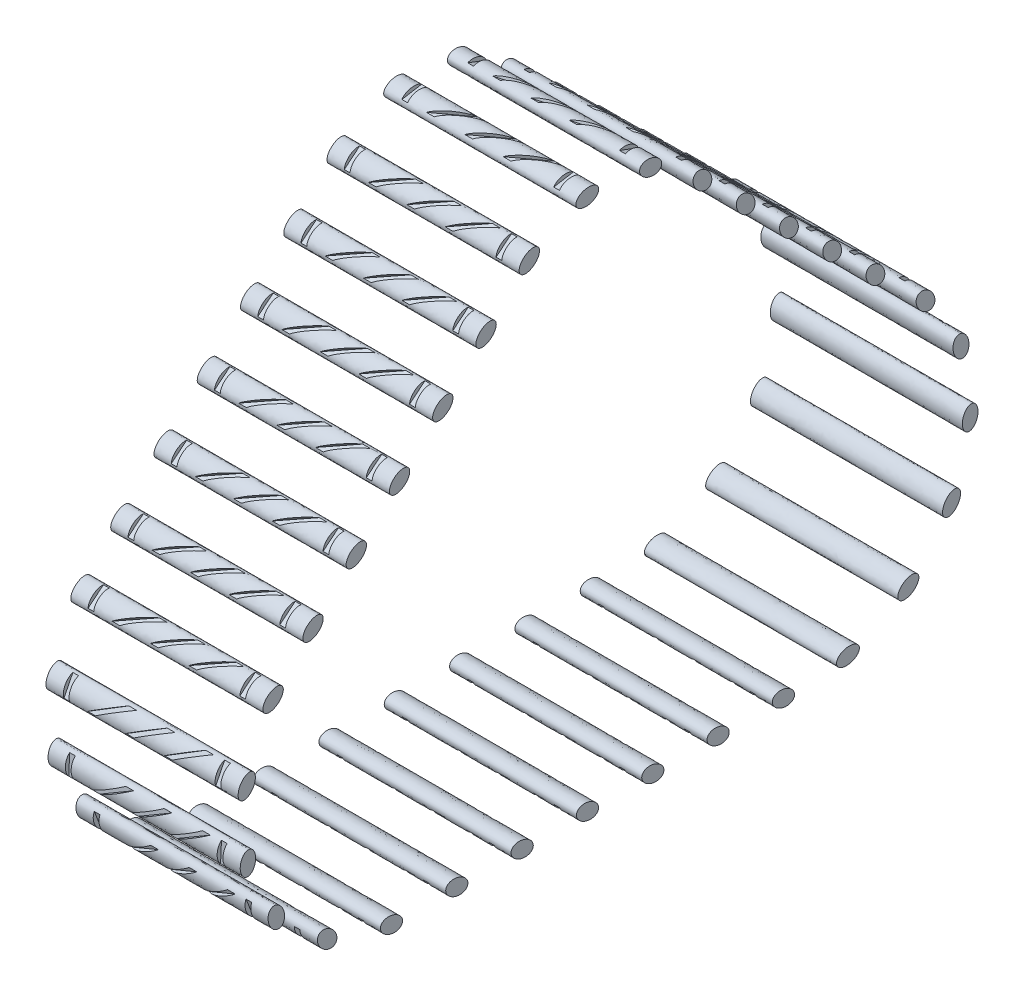
from build123d import *

# Parameters (mm, degrees)
SKETCH_2_RX              = 3
SKETCH_2_RY              = 2
EXTRUDE_1_DEPTH          = 50
SKETCH_5_W               = 1.5
SKETCH_5_H               = 1
CUT_EXTRUDE_2_DEPTH      = 25
CUT_EXTRUDE_4_DEPTH      = 25
PATTERN_LINEAR_1_COUNT   = 2
PATTERN_LINEAR_1_PITCH   = 10
PATTERN_LINEAR_2_COUNT   = 2
PATTERN_LINEAR_2_PITCH   = 10
PATTERN_CIRCULAR_3_COUNT = 3
PATTERN_CIRCULAR_3_ANGLE = 60
PATTERN_CIRCULAR_4_COUNT = 2
PATTERN_CIRCULAR_4_ANGLE = 30
PATTERN_LINEAR_3_COUNT   = 6
PATTERN_LINEAR_3_PITCH   = 15.7
PATTERN_LINEAR_4_COUNT   = 5
PATTERN_LINEAR_4_PITCH   = 15.7
PATTERN_LINEAR_5_COUNT   = 2
PATTERN_LINEAR_5_PITCH   = 15
PATTERN_CIRCULAR_5_COUNT = 6
PATTERN_CIRCULAR_5_ANGLE = 120
PATTERN_LINEAR_6_COUNT   = 2
PATTERN_LINEAR_6_PITCH   = 18
PATTERN_CIRCULAR_6_COUNT = 6
PATTERN_CIRCULAR_6_ANGLE = 120
PATTERN_LINEAR_7_COUNT   = 7
PATTERN_LINEAR_7_PITCH   = 17


with BuildPart() as part:
    # Sketch 2 → Extrude 1 (new body)
    with BuildSketch(Plane(origin=(0, 0, 0), x_dir=(0, 0, -1), z_dir=(1, 0, 0))):
        with Locations(Location((-5.2411758, 96.567762113), (0, 0, 8.868937921))):
            Ellipse(SKETCH_2_RX, SKETCH_2_RY)
    extrude(amount=EXTRUDE_1_DEPTH)

    # Sketch 5 → Cut-Extrude 2 (cut, symmetric)
    with BuildSketch(Plane(origin=(0, 1.757367098, -10.542320534), x_dir=(1, 0, 0), z_dir=(0, -0.164427543, 0.986389164))):
        with Locations((5.25, 97.615322624)):
            Rectangle(SKETCH_5_W, SKETCH_5_H)
    cut_extrude_2 = extrude(amount=CUT_EXTRUDE_2_DEPTH, both=True, mode=Mode.SUBTRACT)

    # Mirror 2: Cut-Extrude 2 across plane
    add(cut_extrude_2.mirror(Plane(origin=(25, 0, 0), x_dir=(0, 0, 1), z_dir=(1, 0, 0))), mode=Mode.SUBTRACT)

    # Sketch 7 → Cut-Extrude 4 (cut, symmetric)
    with BuildSketch(Plane(origin=(23.377948952, 2.219322141, -13.31355606), x_dir=(0.5, -0.142398429, 0.854238074), z_dir=(-0.866025404, -0.082213771, 0.493194582))):
        Polygon((3.244102096, 98.345137773), (4.244102028, 98.34550487), (4.244102028, 97.264960027), (3.244102096, 97.264960027), align=None)
    cut_extrude_4 = extrude(amount=CUT_EXTRUDE_4_DEPTH, both=True, mode=Mode.SUBTRACT)

    # Pattern Linear 1: Cut-Extrude 4 ×2
    with Locations(*[(i * PATTERN_LINEAR_1_PITCH, 0, 0) for i in range(1, PATTERN_LINEAR_1_COUNT)]):
        add(cut_extrude_4, mode=Mode.SUBTRACT)

    # Pattern Linear 2: Cut-Extrude 4 ×2
    with Locations(*[(-i * PATTERN_LINEAR_2_PITCH, 0, 0) for i in range(1, PATTERN_LINEAR_2_COUNT)]):
        add(cut_extrude_4, mode=Mode.SUBTRACT)


with BuildPart() as pattern_circular_3_1:
    # Pattern Circular 3: pattern copy
    add(part.part.rotate(Axis((0, 65, 0), (-1, 0, 0)), 1 * PATTERN_CIRCULAR_3_ANGLE / (PATTERN_CIRCULAR_3_COUNT - 1)))


with BuildPart() as pattern_circular_3_2:
    # Pattern Circular 3: pattern copy
    add(part.part.rotate(Axis((0, 65, 0), (-1, 0, 0)), 2 * PATTERN_CIRCULAR_3_ANGLE / (PATTERN_CIRCULAR_3_COUNT - 1)))


with BuildPart() as pattern_circular_4_1:
    # Pattern Circular 4: pattern copy
    add(part.part.rotate(Axis((0, 65, 0), (1, 0, 0)), 1 * PATTERN_CIRCULAR_4_ANGLE / (PATTERN_CIRCULAR_4_COUNT - 1)))


with BuildPart() as pattern_linear_3_1:
    # Pattern Linear 3: pattern copy
    add(pattern_circular_4_1.part.moved(Location(Vector(0, -0.697148005, 0.716927235) * (1 * PATTERN_LINEAR_3_PITCH))))


with BuildPart() as pattern_linear_3_2:
    # Pattern Linear 3: pattern copy
    add(pattern_circular_4_1.part.moved(Location(Vector(0, -0.697148005, 0.716927235) * (2 * PATTERN_LINEAR_3_PITCH))))


with BuildPart() as pattern_linear_3_3:
    # Pattern Linear 3: pattern copy
    add(pattern_circular_4_1.part.moved(Location(Vector(0, -0.697148005, 0.716927235) * (3 * PATTERN_LINEAR_3_PITCH))))


with BuildPart() as pattern_linear_3_4:
    # Pattern Linear 3: pattern copy
    add(pattern_circular_4_1.part.moved(Location(Vector(0, -0.697148005, 0.716927235) * (4 * PATTERN_LINEAR_3_PITCH))))


with BuildPart() as pattern_linear_3_5:
    # Pattern Linear 3: pattern copy
    add(pattern_circular_4_1.part.moved(Location(Vector(0, -0.697148005, 0.716927235) * (5 * PATTERN_LINEAR_3_PITCH))))


with BuildPart() as pattern_linear_4_1:
    # Pattern Linear 4: pattern copy
    add(pattern_circular_3_2.part.moved(Location(Vector(0, -0.697148005, -0.716927235) * (1 * PATTERN_LINEAR_4_PITCH))))


with BuildPart() as pattern_linear_4_2:
    # Pattern Linear 4: pattern copy
    add(pattern_circular_3_2.part.moved(Location(Vector(0, -0.697148005, -0.716927235) * (2 * PATTERN_LINEAR_4_PITCH))))


with BuildPart() as pattern_linear_4_3:
    # Pattern Linear 4: pattern copy
    add(pattern_circular_3_2.part.moved(Location(Vector(0, -0.697148005, -0.716927235) * (3 * PATTERN_LINEAR_4_PITCH))))


with BuildPart() as pattern_linear_4_4:
    # Pattern Linear 4: pattern copy
    add(pattern_circular_3_2.part.moved(Location(Vector(0, -0.697148005, -0.716927235) * (4 * PATTERN_LINEAR_4_PITCH))))


with BuildPart() as pattern_linear_5_1:
    # Pattern Linear 5: pattern copy
    add(pattern_linear_3_5.part.moved(Location(Vector(0, -0.720832837, 0.693108953) * (1 * PATTERN_LINEAR_5_PITCH))))


with BuildPart() as pattern_circular_5_1:
    # Pattern Circular 5: pattern copy
    add(pattern_linear_5_1.part.rotate(Axis((0, 0.001148754, 52.499211514), (1, 0, 0)), 1 * PATTERN_CIRCULAR_5_ANGLE / (PATTERN_CIRCULAR_5_COUNT - 1)))


with BuildPart() as pattern_circular_5_2:
    # Pattern Circular 5: pattern copy
    add(pattern_linear_5_1.part.rotate(Axis((0, 0.001148754, 52.499211514), (1, 0, 0)), 2 * PATTERN_CIRCULAR_5_ANGLE / (PATTERN_CIRCULAR_5_COUNT - 1)))


with BuildPart() as pattern_circular_5_3:
    # Pattern Circular 5: pattern copy
    add(pattern_linear_5_1.part.rotate(Axis((0, 0.001148754, 52.499211514), (1, 0, 0)), 3 * PATTERN_CIRCULAR_5_ANGLE / (PATTERN_CIRCULAR_5_COUNT - 1)))


with BuildPart() as pattern_circular_5_4:
    # Pattern Circular 5: pattern copy
    add(pattern_linear_5_1.part.rotate(Axis((0, 0.001148754, 52.499211514), (1, 0, 0)), 4 * PATTERN_CIRCULAR_5_ANGLE / (PATTERN_CIRCULAR_5_COUNT - 1)))


with BuildPart() as pattern_circular_5_5:
    # Pattern Circular 5: pattern copy
    add(pattern_linear_5_1.part.rotate(Axis((0, 0.001148754, 52.499211514), (1, 0, 0)), 5 * PATTERN_CIRCULAR_5_ANGLE / (PATTERN_CIRCULAR_5_COUNT - 1)))


with BuildPart() as pattern_linear_6_1:
    # Pattern Linear 6: pattern copy
    add(pattern_linear_4_4.part.moved(Location(Vector(0, -0.689823081, -0.723977981) * (1 * PATTERN_LINEAR_6_PITCH))))


with BuildPart() as pattern_circular_6_1:
    # Pattern Circular 6: pattern copy
    add(pattern_linear_6_1.part.rotate(Axis((0, 0, -52.5), (-1, 0, 0)), 1 * PATTERN_CIRCULAR_6_ANGLE / (PATTERN_CIRCULAR_6_COUNT - 1)))


with BuildPart() as pattern_circular_6_2:
    # Pattern Circular 6: pattern copy
    add(pattern_linear_6_1.part.rotate(Axis((0, 0, -52.5), (-1, 0, 0)), 2 * PATTERN_CIRCULAR_6_ANGLE / (PATTERN_CIRCULAR_6_COUNT - 1)))


with BuildPart() as pattern_circular_6_3:
    # Pattern Circular 6: pattern copy
    add(pattern_linear_6_1.part.rotate(Axis((0, 0, -52.5), (-1, 0, 0)), 3 * PATTERN_CIRCULAR_6_ANGLE / (PATTERN_CIRCULAR_6_COUNT - 1)))


with BuildPart() as pattern_circular_6_4:
    # Pattern Circular 6: pattern copy
    add(pattern_linear_6_1.part.rotate(Axis((0, 0, -52.5), (-1, 0, 0)), 4 * PATTERN_CIRCULAR_6_ANGLE / (PATTERN_CIRCULAR_6_COUNT - 1)))


with BuildPart() as pattern_circular_6_5:
    # Pattern Circular 6: pattern copy
    add(pattern_linear_6_1.part.rotate(Axis((0, 0, -52.5), (-1, 0, 0)), 5 * PATTERN_CIRCULAR_6_ANGLE / (PATTERN_CIRCULAR_6_COUNT - 1)))


with BuildPart() as pattern_linear_7_1:
    # Pattern Linear 7: pattern copy
    add(pattern_circular_5_5.part.moved(Location(Vector(0, 0, -1) * (1 * PATTERN_LINEAR_7_PITCH))))


with BuildPart() as pattern_linear_7_2:
    # Pattern Linear 7: pattern copy
    add(pattern_circular_5_5.part.moved(Location(Vector(0, 0, -1) * (2 * PATTERN_LINEAR_7_PITCH))))


with BuildPart() as pattern_linear_7_3:
    # Pattern Linear 7: pattern copy
    add(pattern_circular_5_5.part.moved(Location(Vector(0, 0, -1) * (3 * PATTERN_LINEAR_7_PITCH))))


with BuildPart() as pattern_linear_7_4:
    # Pattern Linear 7: pattern copy
    add(pattern_circular_5_5.part.moved(Location(Vector(0, 0, -1) * (4 * PATTERN_LINEAR_7_PITCH))))


with BuildPart() as pattern_linear_7_5:
    # Pattern Linear 7: pattern copy
    add(pattern_circular_5_5.part.moved(Location(Vector(0, 0, -1) * (5 * PATTERN_LINEAR_7_PITCH))))


with BuildPart() as pattern_linear_7_6:
    # Pattern Linear 7: pattern copy
    add(pattern_circular_5_5.part.moved(Location(Vector(0, 0, -1) * (6 * PATTERN_LINEAR_7_PITCH))))


solid = Compound([part.part, pattern_circular_3_1.part, pattern_circular_3_2.part, pattern_circular_4_1.part, pattern_linear_3_1.part, pattern_linear_3_2.part, pattern_linear_3_3.part, pattern_linear_3_4.part, pattern_linear_3_5.part, pattern_linear_4_1.part, pattern_linear_4_2.part, pattern_linear_4_3.part, pattern_linear_4_4.part, pattern_linear_5_1.part, pattern_circular_5_1.part, pattern_circular_5_2.part, pattern_circular_5_3.part, pattern_circular_5_4.part, pattern_circular_5_5.part, pattern_linear_6_1.part, pattern_circular_6_1.part, pattern_circular_6_2.part, pattern_circular_6_3.part, pattern_circular_6_4.part, pattern_circular_6_5.part, pattern_linear_7_1.part, pattern_linear_7_2.part, pattern_linear_7_3.part, pattern_linear_7_4.part, pattern_linear_7_5.part, pattern_linear_7_6.part])
